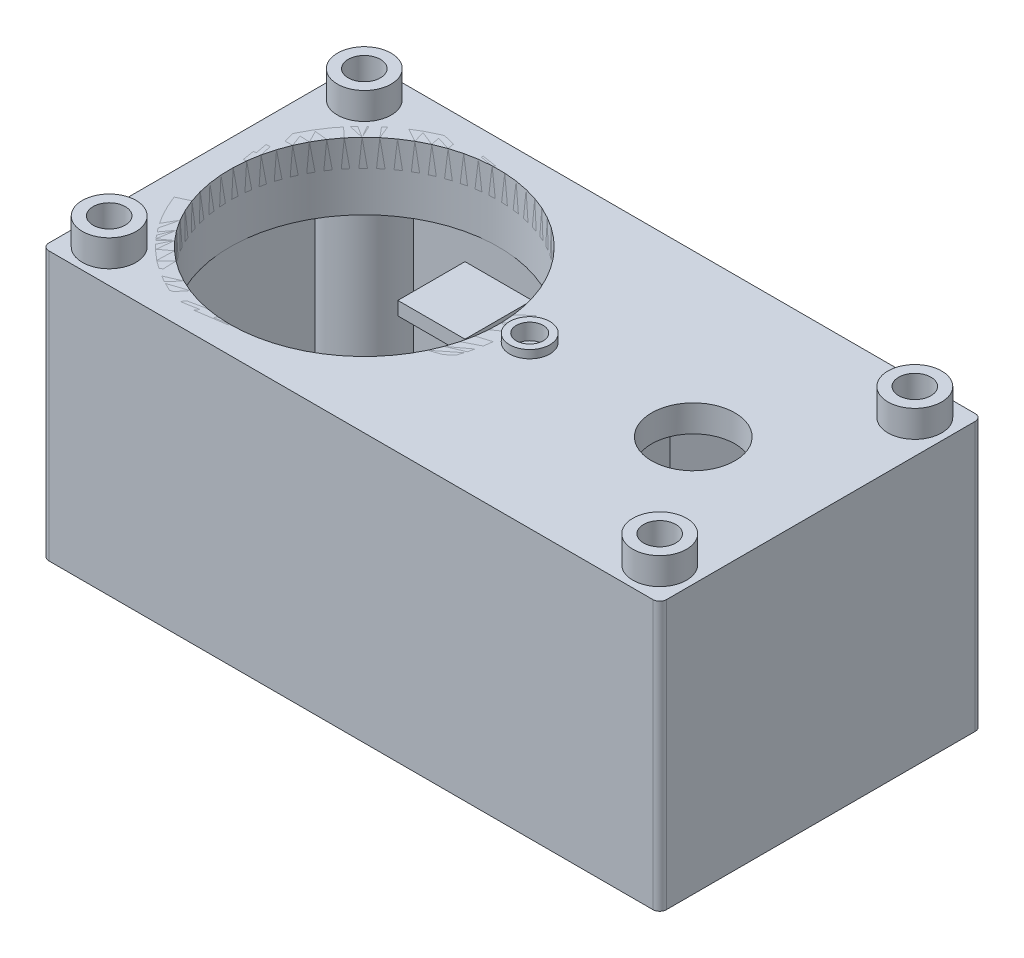
from build123d import *

# Parameters (mm, degrees)
SKETCH2_W           = 23
SKETCH2_H           = 12
SKETCH2_R           = 0.6
BOSS_EXTRUDE1_DEPTH = 10
SHELL1_T            = -1
EXTRUDE_THIN1_START = 10
SKETCH2_3_R         = 1
SKETCH2_3_R_2       = 0.6
EXTRUDE_THIN1_DEPTH = 1
CUT_EXTRUDE1_REACH  = 18.378
SKETCH3_R           = 5
SKETCH3_R_2         = 1.55
SKETCH3_3_R         = 0.75
SKETCH3_3_R_2       = 0.5
EXTRUDE_THIN2_DEPTH = 0.3
CUT_EXTRUDE2_START  = -0.3
SKETCH4_R           = 0.5
CUT_EXTRUDE2_DEPTH  = 0.3
EXTRUDE_THIN3_DEPTH = 5
SKETCH3_6_R         = 5.5
SKETCH3_6_R_2       = 5
EXTRUDE_THIN4_DEPTH = 2.5
BOSS_EXTRUDE3_START = -3.6
SKETCH8_W           = 2.5
SKETCH8_H           = 2.5
BOSS_EXTRUDE3_DEPTH = 0.5
FILLET1_R           = 0.25


with BuildPart() as part:
    # Sketch2 → Boss-Extrude1 (new body)
    with BuildSketch(Plane(origin=(0, 0, 0), x_dir=(1, 0, 0), z_dir=(0, 1, 0))):
        Rectangle(SKETCH2_W, SKETCH2_H)
        with Locations((-10.25, 4.75)):
            Circle(SKETCH2_R, mode=Mode.SUBTRACT)
        with Locations((-10.25, -4.75)):
            Circle(SKETCH2_R, mode=Mode.SUBTRACT)
        with Locations((10.25, -4.75)):
            Circle(SKETCH2_R, mode=Mode.SUBTRACT)
        with Locations((10.25, 4.75)):
            Circle(SKETCH2_R, mode=Mode.SUBTRACT)
    extrude(amount=BOSS_EXTRUDE1_DEPTH)

    # Shell1
    shell1_openings = [part.faces().sort_by_distance(p)[0] for p in [
        (0, 0, 0),
    ]]
    offset(amount=SHELL1_T, openings=shell1_openings)

    # Sketch2_3 → Extrude-Thin1 (add)
    # profile 1 of 4: a face of its own
    with BuildSketch(Plane(origin=(0, 0, 0), x_dir=(1, 0, 0), z_dir=(0, 1, 0)).offset(EXTRUDE_THIN1_START)):
        with Locations((-10.25, 4.75)):
            Circle(SKETCH2_3_R)
        with Locations((-10.25, 4.75)):
            Circle(SKETCH2_3_R_2, mode=Mode.SUBTRACT)
    # profile 2 of 4: a face of its own
    with BuildSketch(Plane(origin=(0, 0, 0), x_dir=(1, 0, 0), z_dir=(0, 1, 0)).offset(EXTRUDE_THIN1_START)):
        with Locations((-10.25, -4.75)):
            Circle(SKETCH2_3_R)
        with Locations((-10.25, -4.75)):
            Circle(SKETCH2_3_R_2, mode=Mode.SUBTRACT)
    # profile 3 of 4: a face of its own
    with BuildSketch(Plane(origin=(0, 0, 0), x_dir=(1, 0, 0), z_dir=(0, 1, 0)).offset(EXTRUDE_THIN1_START)):
        with Locations((10.25, -4.75)):
            Circle(SKETCH2_3_R)
        with Locations((10.25, -4.75)):
            Circle(SKETCH2_3_R_2, mode=Mode.SUBTRACT)
    # profile 4 of 4: a face of its own
    with BuildSketch(Plane(origin=(0, 0, 0), x_dir=(1, 0, 0), z_dir=(0, 1, 0)).offset(EXTRUDE_THIN1_START)):
        with Locations((10.25, 4.75)):
            Circle(SKETCH2_3_R)
        with Locations((10.25, 4.75)):
            Circle(SKETCH2_3_R_2, mode=Mode.SUBTRACT)
    extrude(amount=EXTRUDE_THIN1_DEPTH)

    # Sketch3 → Cut-Extrude1 (cut, up to next)
    with BuildSketch(Plane(origin=(0, 10, 0), x_dir=(1, 0, 0), z_dir=(0, 1, 0)), mode=Mode.PRIVATE) as cut_extrude1_sk1:
        with Locations((-5.5, 0)):
            Circle(SKETCH3_R)
    cut_extrude1_tool1 = extrude(cut_extrude1_sk1.sketch, amount=-CUT_EXTRUDE1_REACH, mode=Mode.PRIVATE) & part.part
    # Sketch3 → Cut-Extrude1 (cut, up to next)
    with BuildSketch(Plane(origin=(0, 10, 0), x_dir=(1, 0, 0), z_dir=(0, 1, 0)), mode=Mode.PRIVATE) as cut_extrude1_sk2:
        with Locations((6.75, 0)):
            Circle(SKETCH3_R_2)
    cut_extrude1_tool2 = extrude(cut_extrude1_sk2.sketch, amount=-CUT_EXTRUDE1_REACH, mode=Mode.PRIVATE) & part.part
    add(cut_extrude1_tool1.solids().sort_by_distance((-5.5, 10, 0))[0], mode=Mode.SUBTRACT)
    add(cut_extrude1_tool2.solids().sort_by_distance((6.75, 10, 0))[0], mode=Mode.SUBTRACT)

    # Sketch3_3 → Extrude-Thin2 (add)
    with BuildSketch(Plane(origin=(0, 10, 0), x_dir=(1, 0, 0), z_dir=(0, 1, 0))):
        with Locations((0.66, 0)):
            Circle(SKETCH3_3_R)
        with Locations((0.66, 0)):
            Circle(SKETCH3_3_R_2, mode=Mode.SUBTRACT)
    extrude(amount=EXTRUDE_THIN2_DEPTH)

    # Sketch4 → Cut-Extrude2 (cut)
    with BuildSketch(Plane(origin=(0, 10, 0), x_dir=(1, 0, 0), z_dir=(0, 1, 0)).offset(CUT_EXTRUDE2_START)):
        with Locations((0.66, 0)):
            Circle(SKETCH4_R)
    extrude(amount=CUT_EXTRUDE2_DEPTH, mode=Mode.SUBTRACT)

    # Sketch5 → Extrude-Thin3 (add)
    with BuildSketch(Plane.XZ.offset(-9)):
        Polygon((4.126113512, 5), (2.95, 3.823886488), (2.95, -2.926113512), (5.023886488, -5), (4.670333097, -5.353553391), (2.45, -3.133220293), (2.45, 4.030993269), (3.772560121, 5.353553391), align=None)
    extrude(amount=EXTRUDE_THIN3_DEPTH)

    # Sketch8 → Boss-Extrude3 (add)
    with BuildSketch(Plane(origin=(0, 10, 0), x_dir=(1, 0, 0), z_dir=(0, 1, 0)).offset(BOSS_EXTRUDE3_START)):
        with Locations((-5.5, 3.75)):
            Rectangle(SKETCH8_W, SKETCH8_H)
        with Locations((-5.5, -3.75)):
            Rectangle(SKETCH8_W, SKETCH8_H)
    extrude(amount=-BOSS_EXTRUDE3_DEPTH)

    # Fillet1
    fillet1_edges = [part.edges().sort_by_distance(p)[0] for p in [
        (-11.5, 5, 6),
        (-11.5, 5, -6),
        (11.5, 5, 6),
        (11.5, 5, -6),
    ]]
    fillet(fillet1_edges, radius=FILLET1_R)


with BuildPart() as body_2:
    # Sketch3_6 → Extrude-Thin4 (new body)
    with BuildSketch(Plane(origin=(0, 10, 0), x_dir=(1, 0, 0), z_dir=(0, 1, 0))):
        with Locations((-5.5, 0)):
            Circle(SKETCH3_6_R)
        with Locations((-5.5, 0)):
            Circle(SKETCH3_6_R_2, mode=Mode.SUBTRACT)
    extrude(amount=-EXTRUDE_THIN4_DEPTH)


solid = Compound([part.part, body_2.part])
